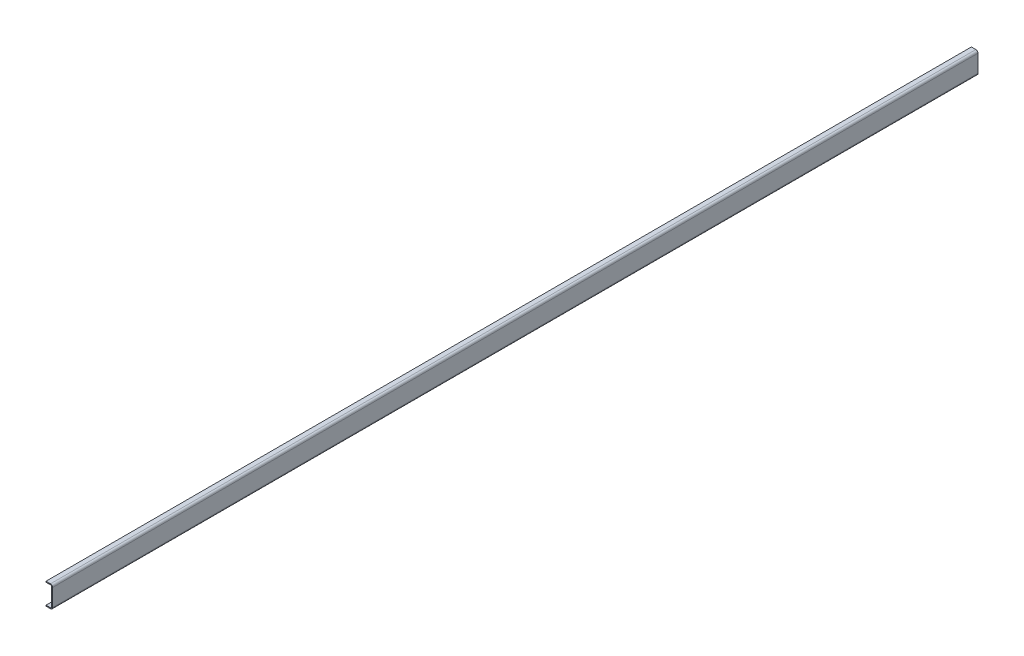
from build123d import *

# Parameters (mm, degrees)
BASE_EXTRUDE_THIN_DEPTH = 9779
INSIDE_BEND_RADIUS_R    = 12.7
OUTSIDE_BEND_RADIUS_R   = 22.225


with BuildPart() as part:
    # Sketch1 → Base-Extrude-Thin (new body)
    with BuildSketch(Plane.XY):
        Polygon((-69.85, 0), (0, 0), (0, 228.6), (-69.85, 228.6), (-69.85, 219.075), (-9.525, 219.075), (-9.525, 9.525), (-69.85, 9.525), align=None)
    extrude(amount=-BASE_EXTRUDE_THIN_DEPTH)

    # Inside Bend Radius
    inside_bend_radius_edges = [part.edges().sort_by_distance(p)[0] for p in [
        (-9.525, 219.075, -4889.5),
        (-9.525, 9.525, -4889.5),
    ]]
    fillet(inside_bend_radius_edges, radius=INSIDE_BEND_RADIUS_R)

    # Outside Bend Radius
    outside_bend_radius_edges = [part.edges().sort_by_distance(p)[0] for p in [
        (0, 0, -4889.5),
        (0, 228.6, -4889.5),
    ]]
    fillet(outside_bend_radius_edges, radius=OUTSIDE_BEND_RADIUS_R)


solid = part.part
